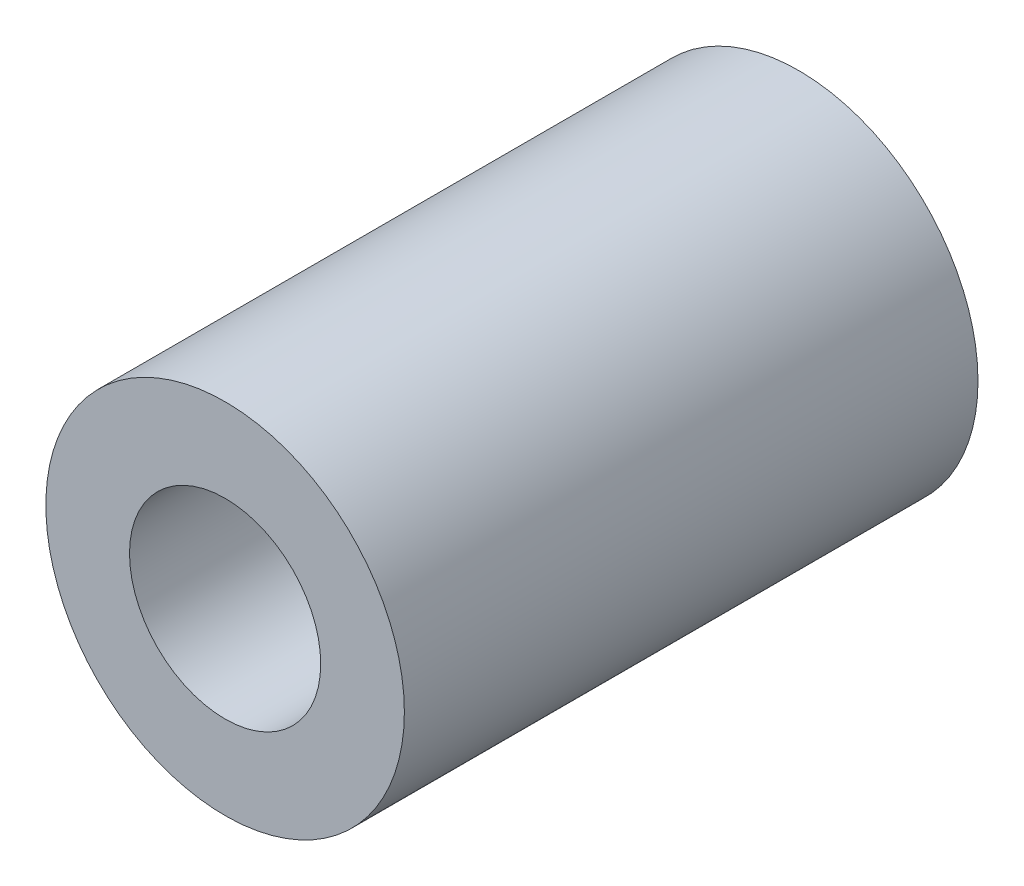
from build123d import *

# Parameters (mm, degrees)
SKETCH_1_R      = 7.5
SKETCH_1_R_2    = 4
EXTRUDE_1_DEPTH = 12


with BuildPart() as part:
    # 草图1 → 凸台-拉伸1 (new body, symmetric)
    with BuildSketch(Plane.XY):
        Circle(SKETCH_1_R)
        Circle(SKETCH_1_R_2, mode=Mode.SUBTRACT)
    extrude(amount=EXTRUDE_1_DEPTH, both=True)


solid = part.part
